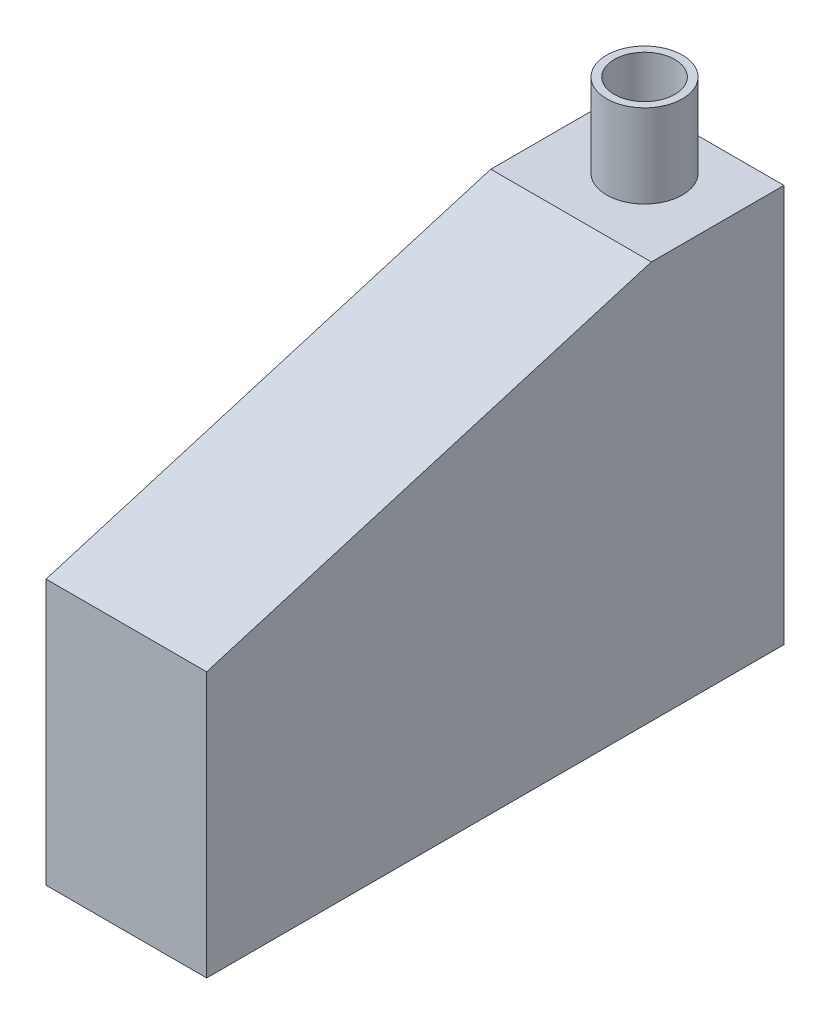
from build123d import *

# Parameters (mm, degrees)
SZKIC1_W                    = 42.4
SZKIC1_H                    = 152.4
SZKIC1_W_2                  = 40
SZKIC1_H_2                  = 150
DODANIE_WYCI_GNI_CIE1_DEPTH = 70
SZKIC1_2_W                  = 40
SZKIC1_2_H                  = 150
DODANIE_WYCI_GNI_CIE2_DEPTH = 2
DODANIE_WYCI_GNI_CIE3_DEPTH = 42.4
WYTNIJ_WYCI_GNI_CIE1_START  = -1.2
WYTNIJ_WYCI_GNI_CIE1_DEPTH  = 39.6
SZKIC3_R                    = 10
SZKIC3_R_2                  = 8
DODANIE_WYCI_GNI_CIE4_DEPTH = 22
WYTNIJ_WYCI_GNI_CIE2_REACH  = 107
SZKIC3_2_R                  = 10
SZKIC3_2_R_2                = 8


with BuildPart() as part:
    # Szkic1 → Dodanie-wyci_gni_cie1 (new body)
    with BuildSketch(Plane(origin=(0, 0, 0), x_dir=(1, 0, 0), z_dir=(0, 1, 0))):
        Rectangle(SZKIC1_W, SZKIC1_H)
        Rectangle(SZKIC1_W_2, SZKIC1_H_2, mode=Mode.SUBTRACT)
    extrude(amount=DODANIE_WYCI_GNI_CIE1_DEPTH)

    # Szkic1_2 → Dodanie-wyci_gni_cie2 (add)
    with BuildSketch(Plane(origin=(0, 0, 0), x_dir=(1, 0, 0), z_dir=(0, 1, 0))):
        Rectangle(SZKIC1_2_W, SZKIC1_2_H)
    extrude(amount=DODANIE_WYCI_GNI_CIE2_DEPTH)

    # Szkic2 → Dodanie-wyci_gni_cie3 (add)
    with BuildSketch(Plane.ZY.offset(21.2)):
        Polygon((-76.2, 70), (-76.2, 105), (-41.2, 105), (76.2, 70), align=None)
    extrude(amount=-DODANIE_WYCI_GNI_CIE3_DEPTH)

    # Szkic2_4 → Wytnij-wyci_gni_cie1 (cut)
    with BuildSketch(Plane.ZY.offset(21.2).offset(WYTNIJ_WYCI_GNI_CIE1_START)):
        Polygon((-75, 103.8), (-75, 70), (71.999788693, 70), (-41.375068449, 103.8), align=None)
    extrude(amount=-WYTNIJ_WYCI_GNI_CIE1_DEPTH, mode=Mode.SUBTRACT)

    # Szkic3 → Dodanie-wyci_gni_cie4 (add)
    with BuildSketch(Plane(origin=(0, 105, 0), x_dir=(1, 0, 0), z_dir=(0, 1, 0))):
        with Locations((0, 60.59151108)):
            Circle(SZKIC3_R)
        with Locations((0, 60.59151108)):
            Circle(SZKIC3_R_2, mode=Mode.SUBTRACT)
    extrude(amount=DODANIE_WYCI_GNI_CIE4_DEPTH)

    # Szkic3_2 → Wytnij-wyci_gni_cie2 (cut, up to next)
    with BuildSketch(Plane(origin=(0, 105, 0), x_dir=(1, 0, 0), z_dir=(0, 1, 0)), mode=Mode.PRIVATE) as wytnij_wyci_gni_cie2_sk1:
        with Locations((0, 60.59151108)):
            Circle(SZKIC3_2_R)
        with Locations((0, 60.59151108)):
            Circle(SZKIC3_2_R_2, mode=Mode.SUBTRACT)
    wytnij_wyci_gni_cie2_tool1 = extrude(wytnij_wyci_gni_cie2_sk1.sketch, amount=-WYTNIJ_WYCI_GNI_CIE2_REACH, mode=Mode.PRIVATE) & part.part
    add(wytnij_wyci_gni_cie2_tool1.solids().sort_by_distance((-9.717157, 105, -60.591511))[0], mode=Mode.SUBTRACT)


solid = part.part
